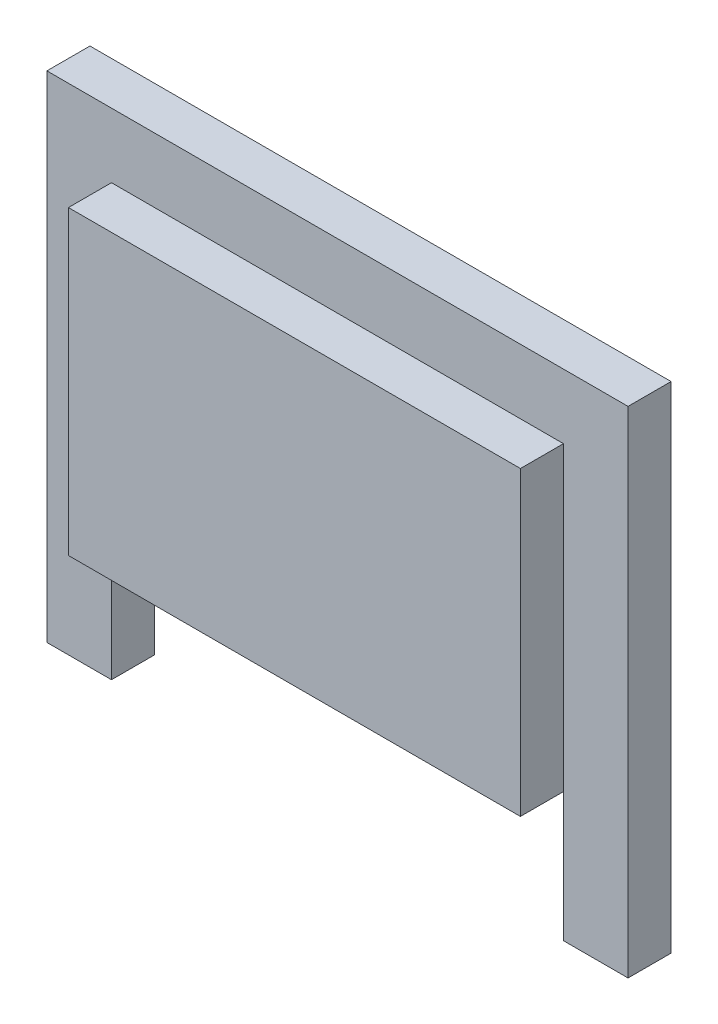
from build123d import *

# Parameters (mm, degrees)
SKETCH1_W           = 27
SKETCH1_H           = 23
BOSS_EXTRUDE1_DEPTH = 2
SKETCH2_W           = 21
SKETCH2_H           = 14
BOSS_EXTRUDE2_DEPTH = 2
SKETCH3_W           = 21
SKETCH3_H           = 6
CUT_EXTRUDE1_DEPTH  = 2


with BuildPart() as part:
    # Sketch1 → Boss-Extrude1 (new body)
    with BuildSketch(Plane.XY):
        Rectangle(SKETCH1_W, SKETCH1_H)
    extrude(amount=BOSS_EXTRUDE1_DEPTH)

    # Sketch2 → Boss-Extrude2 (add)
    with BuildSketch(Plane.XY.offset(2)):
        with Locations((0, 1.5)):
            Rectangle(SKETCH2_W, SKETCH2_H)
    extrude(amount=BOSS_EXTRUDE2_DEPTH)

    # Sketch3 → Cut-Extrude1 (cut)
    with BuildSketch(Plane.XY.offset(2)):
        with Locations((0, -8.5)):
            Rectangle(SKETCH3_W, SKETCH3_H)
    extrude(amount=-CUT_EXTRUDE1_DEPTH, mode=Mode.SUBTRACT)


solid = part.part
